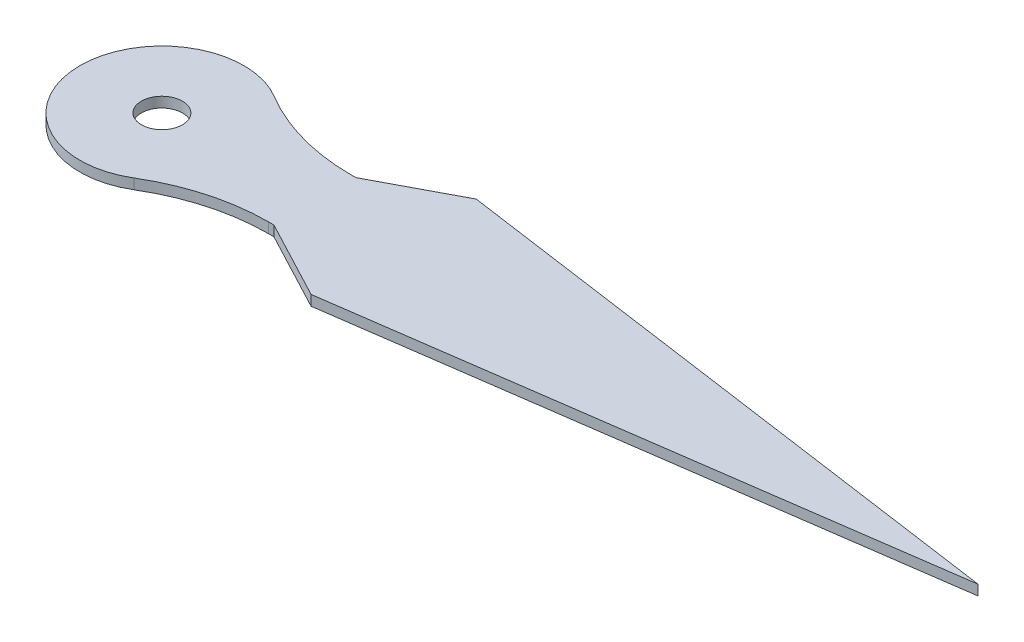
from build123d import *

# Parameters (mm, degrees)
BOSS_EXTRUDE2_DEPTH = 0.5
SKETCH3_R           = 1
CUT_EXTRUDE2_DEPTH  = 1.5
FILLET1_R           = 10


with BuildPart() as part:
    # Sketch1 → Boss-Extrude2 (new body)
    with BuildSketch(Plane(origin=(0, 0, 0), x_dir=(1, 0, 0), z_dir=(0, 1, 0))):
        with BuildLine():
            Line((39.801772908, 0), (11.302617333, 4.027174803))
            Line((11.302617333, 4.027174803), (7.464101615, 2))
            Line((7.464101615, 2), (3.464101615, 2))
            ThreePointArc((3.464101615, 2), (-4, 0), (3.464101615, -2))
            Line((3.464101615, -2), (7.464101615, -2))
            Line((7.464101615, -2), (11.302617333, -4.027174803))
            Line((11.302617333, -4.027174803), (39.801772908, 0))
        make_face()
    extrude(amount=BOSS_EXTRUDE2_DEPTH)

    # Sketch3 → Cut-Extrude2 (cut, through all)
    with BuildSketch(Plane(origin=(0, 0.5, 0), x_dir=(1, 0, 0), z_dir=(0, 1, 0))):
        Circle(SKETCH3_R)
    extrude(amount=-CUT_EXTRUDE2_DEPTH, mode=Mode.SUBTRACT)

    # Fillet1
    fillet1_edges = [part.edges().sort_by_distance(p)[0] for p in [
        (3.464101615, 0.25, 2),
        (3.464101615, 0.25, -2),
    ]]
    fillet(fillet1_edges, radius=FILLET1_R)


solid = part.part
